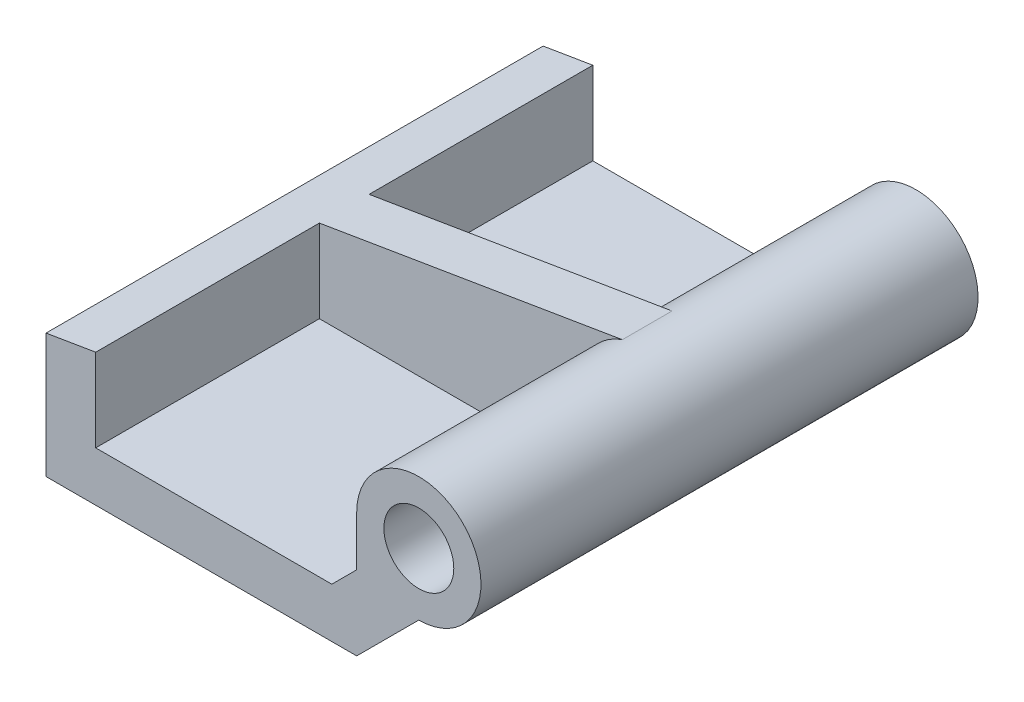
from build123d import *

# Parameters (mm, degrees)
SKETCH1_W                       = 19.05
SKETCH1_H                       = 6.35
BOSS_EXTRUDE1_DEPTH             = 25.4
SKETCH2_R                       = 3.175
BOSS_EXTRUDE3_DEPTH             = 25.4
CUT_EXTRUDE5_DEPTH              = 11.43
CUT_EXTRUDE6_DEPTH              = 26.4
CUT_EXTRUDE9_DEPTH              = 11.43
F_9_64_0_14063_DIAMETER_HOLE3_D = 3.572002


with BuildPart() as part:
    # Sketch1 → Boss-Extrude1 (new body)
    with BuildSketch(Plane.XY):
        Polygon((24.387960916, 24.466176471), (24.387960916, 21.291176471), (5.337960916, 21.291176471), align=None)
        with Locations((14.862960916, 18.116176471)):
            Rectangle(SKETCH1_W, SKETCH1_H)
    extrude(amount=-BOSS_EXTRUDE1_DEPTH)

    # Sketch2 → Boss-Extrude3 (add)
    with BuildSketch(Plane.XY):
        with Locations((24.387960916, 21.291176471)):
            Circle(SKETCH2_R)
    extrude(amount=-BOSS_EXTRUDE3_DEPTH)

    # Sketch9 → Cut-Extrude5 (cut)
    with BuildSketch(Plane.XY):
        with BuildLine():
            Line((23.358231186, 24.294554849), (7.877960916, 21.714509804))
            Line((7.877960916, 21.714509804), (7.877960916, 17.481176471))
            Line((7.877960916, 17.481176471), (19.942960916, 17.481176471))
            Line((19.942960916, 17.481176471), (21.212960916, 18.751176471))
            Line((21.212960916, 18.751176471), (21.212960916, 21.291176471))
            ThreePointArc((21.212960916, 21.291176471), (21.804357145, 23.136607736), (23.358231186, 24.294554849))
        make_face()
    extrude(amount=-CUT_EXTRUDE5_DEPTH, mode=Mode.SUBTRACT)

    # Sketch10 → Cut-Extrude6 (cut, through all)
    with BuildSketch(Plane.XY):
        Polygon((24.387960916, 18.116176471), (21.212960916, 14.941176471), (24.387960916, 14.941176471), align=None)
    extrude(amount=-CUT_EXTRUDE6_DEPTH, mode=Mode.SUBTRACT)

    # Sketch17 → Cut-Extrude9 (cut)
    with BuildSketch(Plane(origin=(0, 0, -25.4), x_dir=(-1, 0, 0), z_dir=(0, 0, -1))):
        with BuildLine():
            Line((-7.877960916, 21.714509804), (-23.358231186, 24.294554849))
            ThreePointArc((-23.358231186, 24.294554849), (-21.804357145, 23.136607736), (-21.212960916, 21.291176471))
            Line((-21.212960916, 21.291176471), (-21.212960916, 18.751176471))
            Line((-21.212960916, 18.751176471), (-19.942960916, 17.481176471))
            Line((-19.942960916, 17.481176471), (-7.877960916, 17.481176471))
            Line((-7.877960916, 17.481176471), (-7.877960916, 21.714509804))
        make_face()
    extrude(amount=-CUT_EXTRUDE9_DEPTH, mode=Mode.SUBTRACT)

    # 9/64 (0.14063) Diameter Hole3 (through all)
    with Locations(Plane(origin=(24.387960916, 21.291176471, 0), x_dir=(1, 0, 0), z_dir=(0, 0, 1))):
        with Locations((0, 0)):
            Hole(F_9_64_0_14063_DIAMETER_HOLE3_D / 2)


solid = part.part
